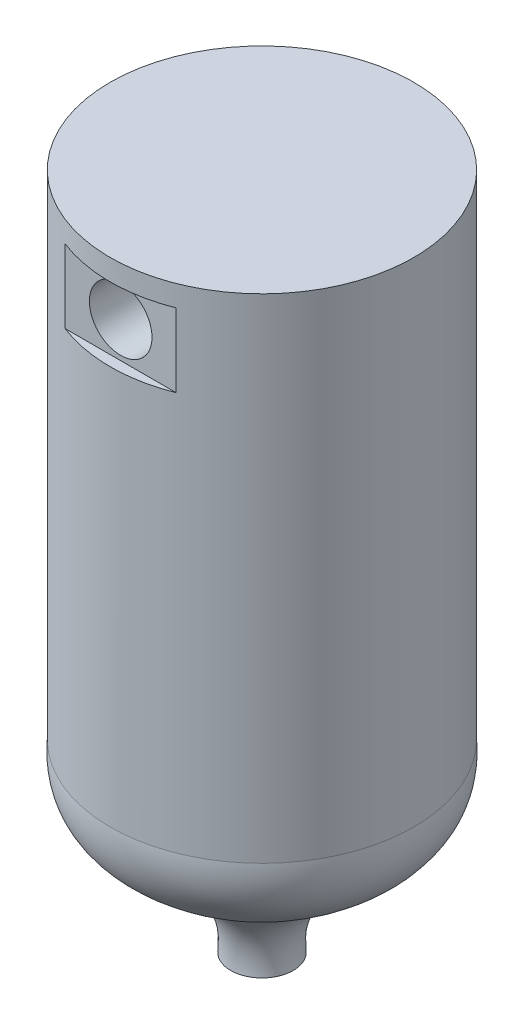
from build123d import *

# Parameters (mm, degrees)
SKETCH3_R               = 0.8
CUT_EXTRUDE1_DEPTH      = 2
CUT_EXTRUDE2_START      = 2
SKETCH4_R               = 0.8
CUT_EXTRUDE2_DEPTH      = 2
CUT_EXTRUDE3_DEPTH      = 5
CUT_EXTRUDE3_DEPTH_BACK = 5
SKETCH6_W               = 0.268563898
SKETCH6_H               = 1.87642035


with BuildPart() as part:
    # Sketch1 → Revolve1 (revolve)
    with BuildSketch(Plane.XY):
        with BuildLine():
            Line((-3.879111396, 0), (-3.879111396, -12))
            Line((-3.879111396, -12), (-3.879111396, -12.602750297))
            add(Edge.make_bspline(
                [(-3.879111396, -12.602750297), (-4.098454424, -15.2494219), (-0.534839258, -14.725941394), (-0.8, -17.31657115)],
                knots=[0, 0, 0, 0, 1, 1, 1, 1], degree=3))
            Line((-0.8, -17.31657115), (0, -17.31657115))
            Line((0, -17.31657115), (0, 0))
            Line((0, 0), (-3.879111396, 0))
        make_face()
    revolve(axis=Axis((0, 0, 0), (0, -1, 0)))

    # Sketch3 → Cut-Extrude1 (cut)
    with BuildSketch(Plane.XY.offset(3.9)):
        with Locations((0, -1.5)):
            Circle(SKETCH3_R)
    extrude(amount=-CUT_EXTRUDE1_DEPTH, mode=Mode.SUBTRACT)

    # Sketch4 → Cut-Extrude2 (cut)
    with BuildSketch(Plane.XY.offset(-3.9).offset(CUT_EXTRUDE2_START)):
        with Locations((0, -1.5)):
            Circle(SKETCH4_R)
    extrude(amount=-CUT_EXTRUDE2_DEPTH, mode=Mode.SUBTRACT)

    # Sketch6 → Cut-Extrude3 (cut, two sides: drawn at the far end of the back side and taken through both)
    with BuildSketch(Plane(origin=(0, 0, 0), x_dir=(0, 0, -1), z_dir=(1, 0, 0)).offset(-CUT_EXTRUDE3_DEPTH_BACK)):
        with Locations((-3.744829447, -1.477966688)):
            Rectangle(SKETCH6_W, SKETCH6_H)
    extrude(amount=CUT_EXTRUDE3_DEPTH + CUT_EXTRUDE3_DEPTH_BACK, mode=Mode.SUBTRACT)


solid = part.part
